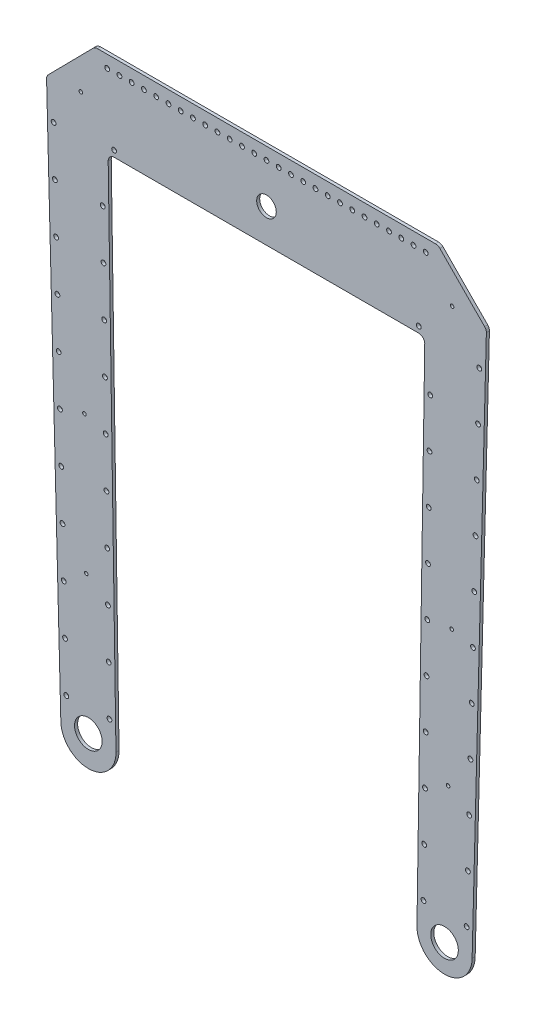
from build123d import *

# Parameters (mm, degrees)
SKETCH1_R           = 14.2875
SKETCH1_R_2         = 2.4892
SKETCH1_R_3         = 1.8288
SKETCH1_R_4         = 10.16
BOSS_EXTRUDE1_DEPTH = 3.175
FILLET1_R           = 6.35


with BuildPart() as part:
    # Sketch1 → Boss-Extrude1 (new body)
    with BuildSketch(Plane.XY):
        with BuildLine():
            Line((431.8, 25.4), (76.2, 25.4))
            Line((76.2, 25.4), (26.059319149, -25.4))
            Line((26.059319149, -25.4), (40.894, -596.9))
            ThreePointArc((40.894, -596.9), (69.687933371, -625.474161286), (98.040645192, -596.462146109))
            Line((98.040645192, -596.462146109), (89.873122894, -63.5))
            Line((89.873122894, -63.5), (418.126877106, -63.5))
            Line((418.126877106, -63.5), (409.959354808, -596.462146109))
            ThreePointArc((409.959354808, -596.462146109), (438.312066629, -625.474161286), (467.106, -596.9))
            Line((467.106, -596.9), (481.940680851, -25.4))
            Line((481.940680851, -25.4), (431.8, 25.4))
        make_face()
        with Locations((69.402383578, -593.962825081)):
            Circle(SKETCH1_R, mode=Mode.SUBTRACT)
        with Locations((46.582379595, -571.328944019)):
            Circle(SKETCH1_R_2, mode=Mode.SUBTRACT)
        with Locations((91.28656025, -570.142707564)):
            Circle(SKETCH1_R_2, mode=Mode.SUBTRACT)
        with Locations((45.264185314, -520.546049618)):
            Circle(SKETCH1_R_2, mode=Mode.SUBTRACT)
        with Locations((43.945991034, -469.763155216)):
            Circle(SKETCH1_R_2, mode=Mode.SUBTRACT)
        with Locations((90.508153333, -519.348671668)):
            Circle(SKETCH1_R_2, mode=Mode.SUBTRACT)
        with Locations((89.729746417, -468.554635771)):
            Circle(SKETCH1_R_2, mode=Mode.SUBTRACT)
        with Locations((67.240460084, -451.479225721)):
            Circle(SKETCH1_R_3, mode=Mode.SUBTRACT)
        with Locations((42.627796754, -418.980260814)):
            Circle(SKETCH1_R_2, mode=Mode.SUBTRACT)
        with Locations((88.9513395, -417.760599874)):
            Circle(SKETCH1_R_2, mode=Mode.SUBTRACT)
        with Locations((41.309602474, -368.197366412)):
            Circle(SKETCH1_R_2, mode=Mode.SUBTRACT)
        with Locations((39.991408193, -317.41447201)):
            Circle(SKETCH1_R_2, mode=Mode.SUBTRACT)
        with Locations((65.373280571, -308.991459085)):
            Circle(SKETCH1_R_3, mode=Mode.SUBTRACT)
        with Locations((88.172932583, -366.966563978)):
            Circle(SKETCH1_R_2, mode=Mode.SUBTRACT)
        with Locations((87.394525667, -316.172528081)):
            Circle(SKETCH1_R_2, mode=Mode.SUBTRACT)
        with Locations((416.71343975, -570.142707564)):
            Circle(SKETCH1_R_2, mode=Mode.SUBTRACT)
        with Locations((438.531, -596.9)):
            Circle(SKETCH1_R, mode=Mode.SUBTRACT)
        with Locations((461.417620405, -571.328944019)):
            Circle(SKETCH1_R_2, mode=Mode.SUBTRACT)
        with Locations((417.491846667, -519.348671668)):
            Circle(SKETCH1_R_2, mode=Mode.SUBTRACT)
        with Locations((418.270253583, -468.554635771)):
            Circle(SKETCH1_R_2, mode=Mode.SUBTRACT)
        with Locations((462.735814686, -520.546049618)):
            Circle(SKETCH1_R_2, mode=Mode.SUBTRACT)
        with Locations((464.054008966, -469.763155216)):
            Circle(SKETCH1_R_2, mode=Mode.SUBTRACT)
        with Locations((419.0486605, -417.760599874)):
            Circle(SKETCH1_R_2, mode=Mode.SUBTRACT)
        with Locations((442.219071981, -454.447733872)):
            Circle(SKETCH1_R_3, mode=Mode.SUBTRACT)
        with Locations((465.372203246, -418.980260814)):
            Circle(SKETCH1_R_2, mode=Mode.SUBTRACT)
        with Locations((419.827067417, -366.966563978)):
            Circle(SKETCH1_R_2, mode=Mode.SUBTRACT)
        with Locations((420.605474333, -316.172528081)):
            Circle(SKETCH1_R_2, mode=Mode.SUBTRACT)
        with Locations((466.690397526, -368.197366412)):
            Circle(SKETCH1_R_2, mode=Mode.SUBTRACT)
        with Locations((445.916762629, -311.995717095)):
            Circle(SKETCH1_R_3, mode=Mode.SUBTRACT)
        with Locations((468.008591807, -317.41447201)):
            Circle(SKETCH1_R_2, mode=Mode.SUBTRACT)
        with Locations((38.673213913, -266.631577608)):
            Circle(SKETCH1_R_2, mode=Mode.SUBTRACT)
        with Locations((86.61611875, -265.378492184)):
            Circle(SKETCH1_R_2, mode=Mode.SUBTRACT)
        with Locations((37.355019633, -215.848683206)):
            Circle(SKETCH1_R_2, mode=Mode.SUBTRACT)
        with Locations((36.036825353, -165.065788804)):
            Circle(SKETCH1_R_2, mode=Mode.SUBTRACT)
        with Locations((85.837711834, -214.584456288)):
            Circle(SKETCH1_R_2, mode=Mode.SUBTRACT)
        with Locations((85.059304917, -163.790420391)):
            Circle(SKETCH1_R_2, mode=Mode.SUBTRACT)
        with Locations((34.718631073, -114.282894402)):
            Circle(SKETCH1_R_2, mode=Mode.SUBTRACT)
        with Locations((33.400436792, -63.5)):
            Circle(SKETCH1_R_2, mode=Mode.SUBTRACT)
        with Locations((84.280898001, -112.996384494)):
            Circle(SKETCH1_R_2, mode=Mode.SUBTRACT)
        with Locations((61.612453458, -21.996099229)):
            Circle(SKETCH1_R_3, mode=Mode.SUBTRACT)
        with Locations((88.9, 12.7)):
            Circle(SKETCH1_R_2, mode=Mode.SUBTRACT)
        with Locations((101.6, 12.7)):
            Circle(SKETCH1_R_2, mode=Mode.SUBTRACT)
        with Locations((114.3, 12.7)):
            Circle(SKETCH1_R_2, mode=Mode.SUBTRACT)
        with Locations((127, 12.7)):
            Circle(SKETCH1_R_2, mode=Mode.SUBTRACT)
        with Locations((139.7, 12.7)):
            Circle(SKETCH1_R_2, mode=Mode.SUBTRACT)
        with Locations((152.4, 12.7)):
            Circle(SKETCH1_R_2, mode=Mode.SUBTRACT)
        with Locations((165.1, 12.7)):
            Circle(SKETCH1_R_2, mode=Mode.SUBTRACT)
        with Locations((177.8, 12.7)):
            Circle(SKETCH1_R_2, mode=Mode.SUBTRACT)
        with Locations((190.5, 12.7)):
            Circle(SKETCH1_R_2, mode=Mode.SUBTRACT)
        with Locations((203.2, 12.7)):
            Circle(SKETCH1_R_2, mode=Mode.SUBTRACT)
        with Locations((215.9, 12.7)):
            Circle(SKETCH1_R_2, mode=Mode.SUBTRACT)
        with Locations((228.6, 12.7)):
            Circle(SKETCH1_R_2, mode=Mode.SUBTRACT)
        with Locations((241.3, 12.7)):
            Circle(SKETCH1_R_2, mode=Mode.SUBTRACT)
        with Locations((421.38388125, -265.378492184)):
            Circle(SKETCH1_R_2, mode=Mode.SUBTRACT)
        with Locations((469.326786087, -266.631577608)):
            Circle(SKETCH1_R_2, mode=Mode.SUBTRACT)
        with Locations((422.162288166, -214.584456288)):
            Circle(SKETCH1_R_2, mode=Mode.SUBTRACT)
        with Locations((422.940695083, -163.790420391)):
            Circle(SKETCH1_R_2, mode=Mode.SUBTRACT)
        with Locations((470.644980367, -215.848683206)):
            Circle(SKETCH1_R_2, mode=Mode.SUBTRACT)
        with Locations((471.963174647, -165.065788804)):
            Circle(SKETCH1_R_2, mode=Mode.SUBTRACT)
        with Locations((254, 12.7)):
            Circle(SKETCH1_R_2, mode=Mode.SUBTRACT)
        with Locations((266.7, 12.7)):
            Circle(SKETCH1_R_2, mode=Mode.SUBTRACT)
        with Locations((279.4, 12.7)):
            Circle(SKETCH1_R_2, mode=Mode.SUBTRACT)
        with Locations((292.1, 12.7)):
            Circle(SKETCH1_R_2, mode=Mode.SUBTRACT)
        with Locations((304.8, 12.7)):
            Circle(SKETCH1_R_2, mode=Mode.SUBTRACT)
        with Locations((317.5, 12.7)):
            Circle(SKETCH1_R_2, mode=Mode.SUBTRACT)
        with Locations((330.2, 12.7)):
            Circle(SKETCH1_R_2, mode=Mode.SUBTRACT)
        with Locations((342.9, 12.7)):
            Circle(SKETCH1_R_2, mode=Mode.SUBTRACT)
        with Locations((355.6, 12.7)):
            Circle(SKETCH1_R_2, mode=Mode.SUBTRACT)
        with Locations((423.719101999, -112.996384494)):
            Circle(SKETCH1_R_2, mode=Mode.SUBTRACT)
        with Locations((473.281368927, -114.282894402)):
            Circle(SKETCH1_R_2, mode=Mode.SUBTRACT)
        with Locations((474.599563208, -63.5)):
            Circle(SKETCH1_R_2, mode=Mode.SUBTRACT)
        with Locations((368.3, 12.7)):
            Circle(SKETCH1_R_2, mode=Mode.SUBTRACT)
        with Locations((381, 12.7)):
            Circle(SKETCH1_R_2, mode=Mode.SUBTRACT)
        with Locations((393.7, 12.7)):
            Circle(SKETCH1_R_2, mode=Mode.SUBTRACT)
        with Locations((406.4, 12.7)):
            Circle(SKETCH1_R_2, mode=Mode.SUBTRACT)
        with Locations((419.1, 12.7)):
            Circle(SKETCH1_R_2, mode=Mode.SUBTRACT)
        with Locations((446.387546542, -21.996099229)):
            Circle(SKETCH1_R_3, mode=Mode.SUBTRACT)
        with Locations((96.126556205, -57.15)):
            Circle(SKETCH1_R_2, mode=Mode.SUBTRACT)
        with Locations((254, -28.575)):
            Circle(SKETCH1_R_4, mode=Mode.SUBTRACT)
        with Locations((411.873443795, -57.15)):
            Circle(SKETCH1_R_2, mode=Mode.SUBTRACT)
    extrude(amount=BOSS_EXTRUDE1_DEPTH)

    # Fillet1
    fillet1_edges = [part.edges().sort_by_distance(p)[0] for p in [
        (26.059319149, -25.4, 1.5875),
        (76.2, 25.4, 1.5875),
        (431.8, 25.4, 1.5875),
        (481.940680851, -25.4, 1.5875),
        (418.126877106, -63.5, 1.5875),
        (89.873122894, -63.5, 1.5875),
    ]]
    fillet(fillet1_edges, radius=FILLET1_R)


solid = part.part
